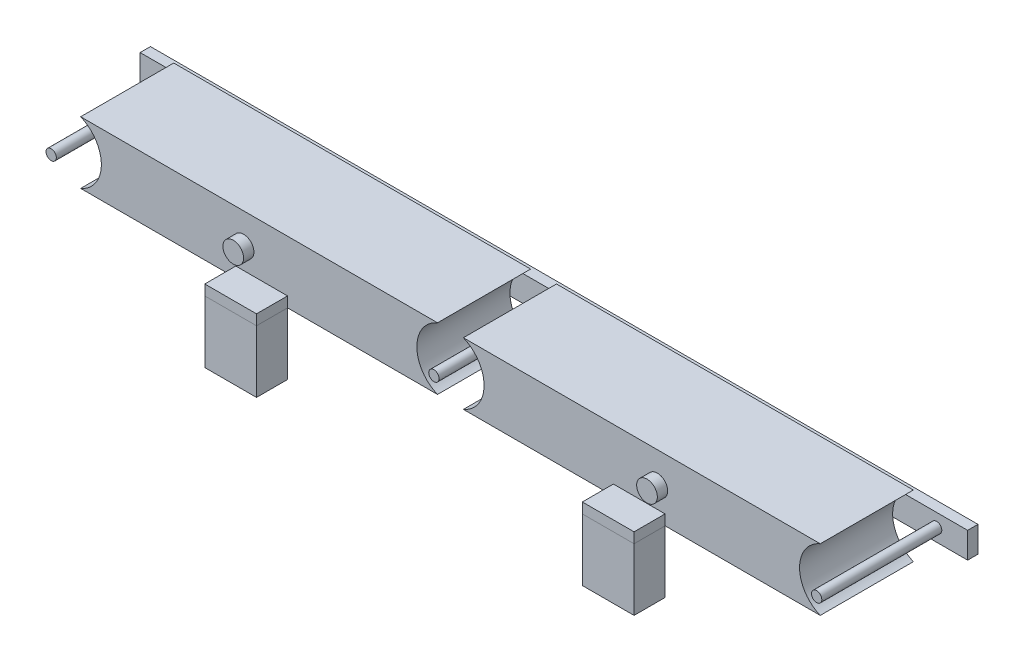
from build123d import *

# Parameters (mm, degrees)
SKETCH1_W             = 800
SKETCH1_H             = 90
BOSS_EXTRUDE1_DEPTH   = 60
SKETCH2_R             = 32.5
CUT_EXTRUDE1_DEPTH    = 110
SKETCH3_W             = 800
SKETCH3_H             = 25
BOSS_EXTRUDE2_DEPTH   = 10
SKETCH4_R             = 10
BOSS_EXTRUDE3_DEPTH   = 20
SKETCH5_R             = 5
BOSS_EXTRUDE5_DEPTH   = 126
SKETCH6_W             = 50
SKETCH6_H             = 150
BOSS_EXTRUDE6_DEPTH   = 10
BOSS_EXTRUDE6_2_DEPTH = 10
SKETCH8_W             = 50
SKETCH8_H             = 30
BOSS_EXTRUDE7_DEPTH   = 60
BOSS_EXTRUDE7_2_DEPTH = 60
BOSS_EXTRUDE7_3_DEPTH = 60
BOSS_EXTRUDE7_4_DEPTH = 60
SKETCH9_R             = 10
BOSS_EXTRUDE8_DEPTH   = 10
SKETCH11_W            = 38.25894648
SKETCH11_H            = 105.501943323
SKETCH11_W_2          = 34.499866654
SKETCH11_H_2          = 108.385350348
CUT_EXTRUDE3_DEPTH    = 100


with BuildPart() as part:
    # Sketch1 → Boss-Extrude1 (new body)
    with BuildSketch(Plane(origin=(0, 0, 0), x_dir=(1, 0, 0), z_dir=(0, 1, 0))):
        Rectangle(SKETCH1_W, SKETCH1_H)
    extrude(amount=BOSS_EXTRUDE1_DEPTH)

    # Sketch2 → Cut-Extrude1 (cut)
    with BuildSketch(Plane.XY.offset(45)):
        with Locations((370, 30)):
            Circle(SKETCH2_R)
        with Locations((-370, 30)):
            Circle(SKETCH2_R)
        with Locations((0, 30)):
            Circle(SKETCH2_R)
    extrude(amount=-CUT_EXTRUDE1_DEPTH, mode=Mode.SUBTRACT)



with BuildPart() as body_2:
    # Sketch3 → Boss-Extrude2 (new body)
    with BuildSketch(Plane(origin=(0, 0, -55), x_dir=(-1, 0, 0), z_dir=(0, 0, -1))):
        with Locations((0, 30)):
            Rectangle(SKETCH3_W, SKETCH3_H)
    extrude(amount=BOSS_EXTRUDE2_DEPTH)


with BuildPart() as part_1:
    add(part.part)

    add(body_2.part)  # Boss-Extrude3 merges body 2
    # Sketch4 → Boss-Extrude3 (add)
    with BuildSketch(Plane(origin=(0, 0, -55), x_dir=(-1, 0, 0), z_dir=(0, 0, -1))):
        with Locations((-200, 30.413322318)):
            Circle(SKETCH4_R)
        with Locations((200, 30.413322318)):
            Circle(SKETCH4_R)
    extrude(amount=-BOSS_EXTRUDE3_DEPTH)

    # Sketch5 → Boss-Extrude5 (add)
    with BuildSketch(Plane(origin=(0, 0, -65), x_dir=(-1, 0, 0), z_dir=(0, 0, -1))):
        with Locations((-370, 30)):
            Circle(SKETCH5_R)
        with Locations((0, 30)):
            Circle(SKETCH5_R)
        with Locations((370, 30)):
            Circle(SKETCH5_R)
    extrude(amount=-BOSS_EXTRUDE5_DEPTH)

    # Sketch9 → Boss-Extrude8 (add)
    with BuildSketch(Plane.XY.offset(45)):
        with Locations((-200, 30.413322318)):
            Circle(SKETCH9_R)
        with Locations((200, 30.413322318)):
            Circle(SKETCH9_R)
    extrude(amount=BOSS_EXTRUDE8_DEPTH)

    # Sketch11 → Cut-Extrude3 (cut)
    with BuildSketch(Plane(origin=(0, 0, 0), x_dir=(1, 0, 0), z_dir=(0, 1, 0))):
        with Locations((395.58737716, -0.634378686)):
            Rectangle(SKETCH11_W, SKETCH11_H)
        with Locations((-395.754238744, 0.807324826)):
            Rectangle(SKETCH11_W_2, SKETCH11_H_2)
    extrude(amount=CUT_EXTRUDE3_DEPTH, mode=Mode.SUBTRACT)


with BuildPart() as body_2_2:
    # Sketch6 → Boss-Extrude6 (new body)
    with BuildSketch(Plane(origin=(0, 10, 0), x_dir=(1, 0, 0), z_dir=(0, 1, 0))):
        with Locations((182.5, 0)):
            Rectangle(SKETCH6_W, SKETCH6_H)
    extrude(amount=-BOSS_EXTRUDE6_DEPTH)


with BuildPart() as body_3:
    # Sketch6 → Boss-Extrude6 2 (new body)
    with BuildSketch(Plane(origin=(0, 10, 0), x_dir=(1, 0, 0), z_dir=(0, 1, 0))):
        with Locations((-182.5, 0)):
            Rectangle(SKETCH6_W, SKETCH6_H)
    extrude(amount=-BOSS_EXTRUDE6_2_DEPTH)


with BuildPart() as body_4:
    # Sketch8 → Boss-Extrude7 (new body)
    with BuildSketch(Plane(origin=(0, 0, 0), x_dir=(1, 0, 0), z_dir=(0, 1, 0))):
        with Locations((-182.5, -60)):
            Rectangle(SKETCH8_W, SKETCH8_H)
    extrude(amount=-BOSS_EXTRUDE7_DEPTH)


with BuildPart() as body_5:
    # Sketch8 → Boss-Extrude7 2 (new body)
    with BuildSketch(Plane(origin=(0, 0, 0), x_dir=(1, 0, 0), z_dir=(0, 1, 0))):
        with Locations((-182.5, 60)):
            Rectangle(SKETCH8_W, SKETCH8_H)
    extrude(amount=-BOSS_EXTRUDE7_2_DEPTH)


with BuildPart() as body_6:
    # Sketch8 → Boss-Extrude7 3 (new body)
    with BuildSketch(Plane(origin=(0, 0, 0), x_dir=(1, 0, 0), z_dir=(0, 1, 0))):
        with Locations((182.5, 60)):
            Rectangle(SKETCH8_W, SKETCH8_H)
    extrude(amount=-BOSS_EXTRUDE7_3_DEPTH)


with BuildPart() as body_7:
    # Sketch8 → Boss-Extrude7 4 (new body)
    with BuildSketch(Plane(origin=(0, 0, 0), x_dir=(1, 0, 0), z_dir=(0, 1, 0))):
        with Locations((182.5, -60)):
            Rectangle(SKETCH8_W, SKETCH8_H)
    extrude(amount=-BOSS_EXTRUDE7_4_DEPTH)


solid = Compound([part_1.part, body_2_2.part, body_3.part, body_4.part, body_5.part, body_6.part, body_7.part])
